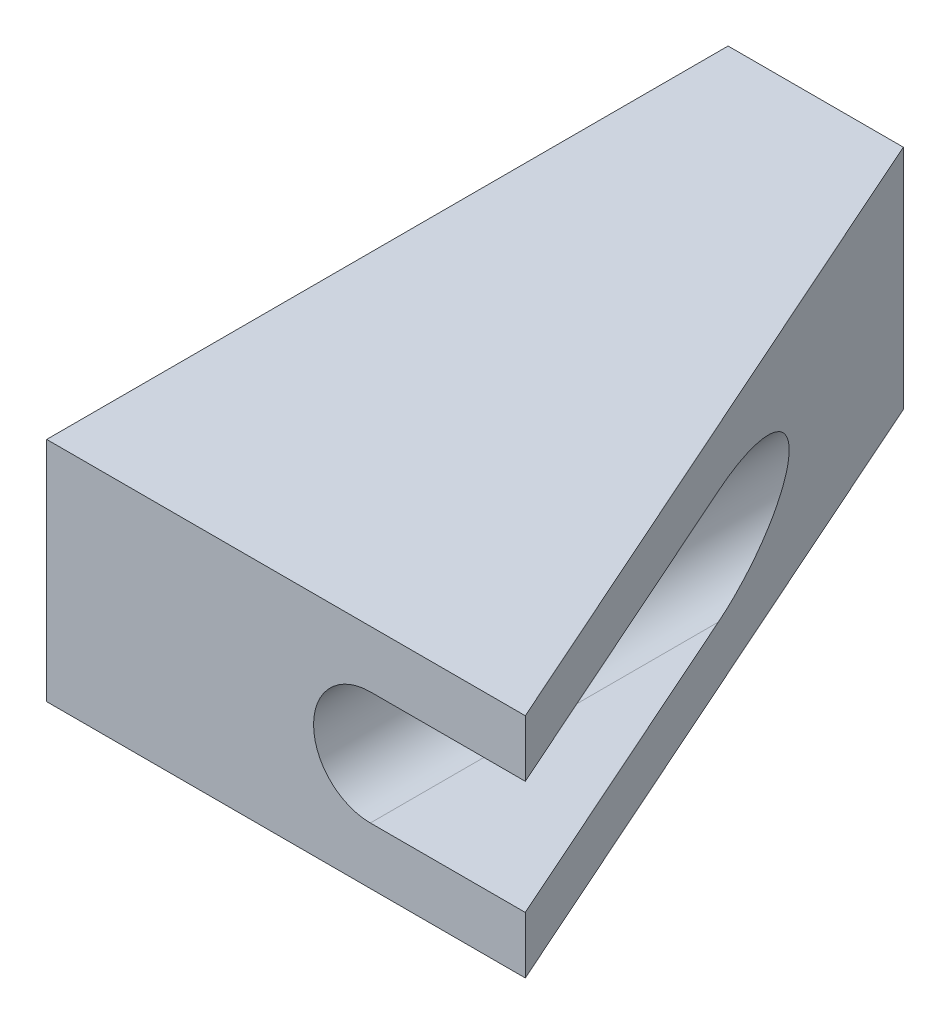
from build123d import *

# Parameters (mm, degrees)
EXTRUDE_1_DEPTH     = 4
SKETCH_2_R          = 1
CUT_EXTRUDE_1_DEPTH = 13
CUT_EXTRUDE_2_DEPTH = 13


with BuildPart() as part:
    # Эскиз1 → Бобышка-Вытянуть1 (new body)
    with BuildSketch(Plane(origin=(0, 0, 0), x_dir=(1, 0, 0), z_dir=(0, 1, 0))):
        Polygon((0, 0), (0, 12), (3.085955121, 12), (8.428699344, 0), align=None)
    extrude(amount=EXTRUDE_1_DEPTH)

    # Эскиз2 → Вырез-Вытянуть1 (cut, through all)
    with BuildSketch(Plane.XY):
        with Locations((5.7, 2)):
            Circle(SKETCH_2_R)
    extrude(amount=-CUT_EXTRUDE_1_DEPTH, mode=Mode.SUBTRACT)

    # Эскиз3 → Вырез-Вытянуть2 (cut, through all)
    with BuildSketch(Plane.XY):
        with BuildLine():
            Line((8.428699344, 3), (5.7, 3))
            ThreePointArc((5.7, 3), (6.407106781, 2.707106781), (6.7, 2))
            ThreePointArc((6.7, 2), (6.407106781, 1.292893219), (5.7, 1))
            Line((5.7, 1), (8.428699344, 1))
            Line((8.428699344, 1), (8.428699344, 3))
        make_face()
    extrude(amount=-CUT_EXTRUDE_2_DEPTH, mode=Mode.SUBTRACT)


solid = part.part
